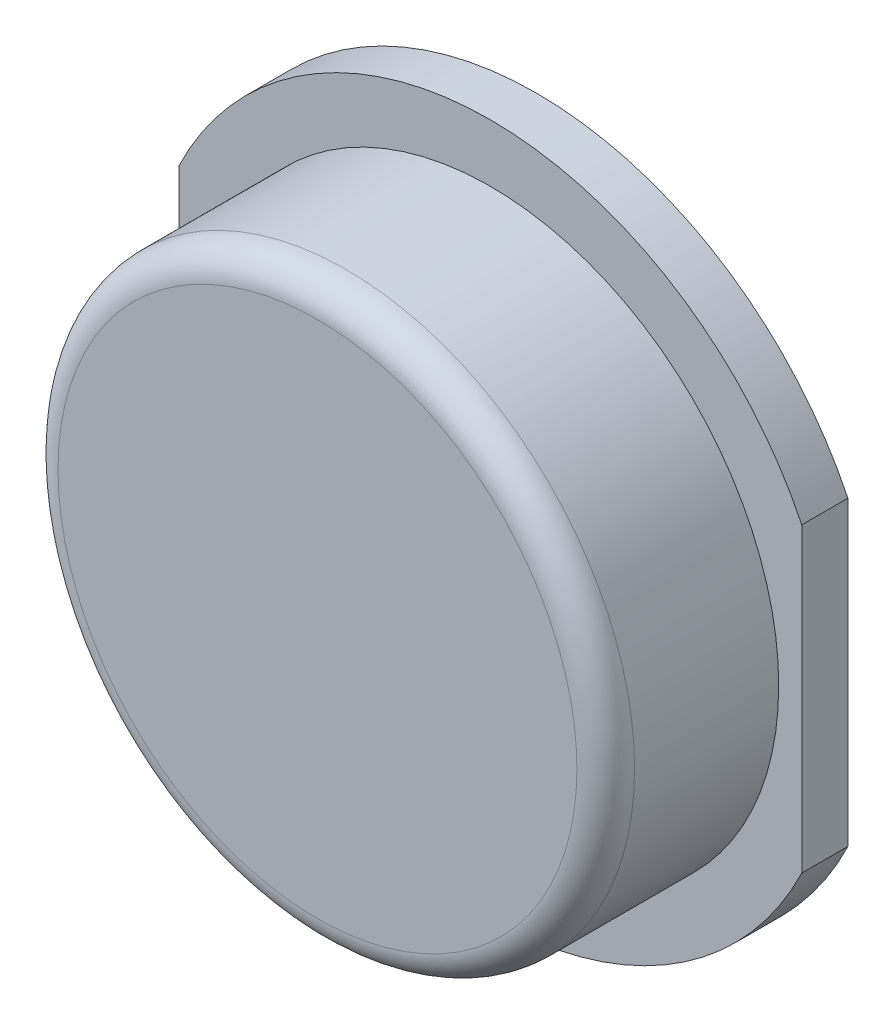
from build123d import *

# Parameters (mm, degrees)
SKETCH_2_R      = 5
EXTRUDE_1_DEPTH = 0.8
SKETCH_2_3_R    = 5
SKETCH_2_3_R_2  = 3.75
EXTRUDE_2_DEPTH = 3.8
SKETCH_3_R      = 3.75
EXTRUDE_3_DEPTH = 0.8
FILLET_1_R      = 0.5


with BuildPart() as part:
    # Sketch 2 → Extrude 1 (new body)
    with BuildSketch(Plane.XY):
        with BuildLine():
            Line((-5.4, 2.615339366), (-5.4, -2.615339366))
            ThreePointArc((-5.4, -2.615339366), (0, -6), (5.4, -2.615339366))
            Line((5.4, -2.615339366), (5.4, 2.615339366))
            ThreePointArc((5.4, 2.615339366), (0, 6), (-5.4, 2.615339366))
        make_face()
        Circle(SKETCH_2_R, mode=Mode.SUBTRACT)
    extrude(amount=EXTRUDE_1_DEPTH)

    # Sketch 2_3 → Extrude 2 (add)
    with BuildSketch(Plane.XY):
        Circle(SKETCH_2_3_R)
        Circle(SKETCH_2_3_R_2, mode=Mode.SUBTRACT)
    extrude(amount=EXTRUDE_2_DEPTH)

    # Sketch 3 → Extrude 3 (add)
    with BuildSketch(Plane.XY.offset(3.8)):
        Circle(SKETCH_3_R)
    extrude(amount=-EXTRUDE_3_DEPTH)

    # Fillet 1
    fillet_1_edges = [part.edges().sort_by_distance(p)[0] for p in [
        (-5, 0, 3.8),
    ]]
    fillet(fillet_1_edges, radius=FILLET_1_R)


solid = part.part
